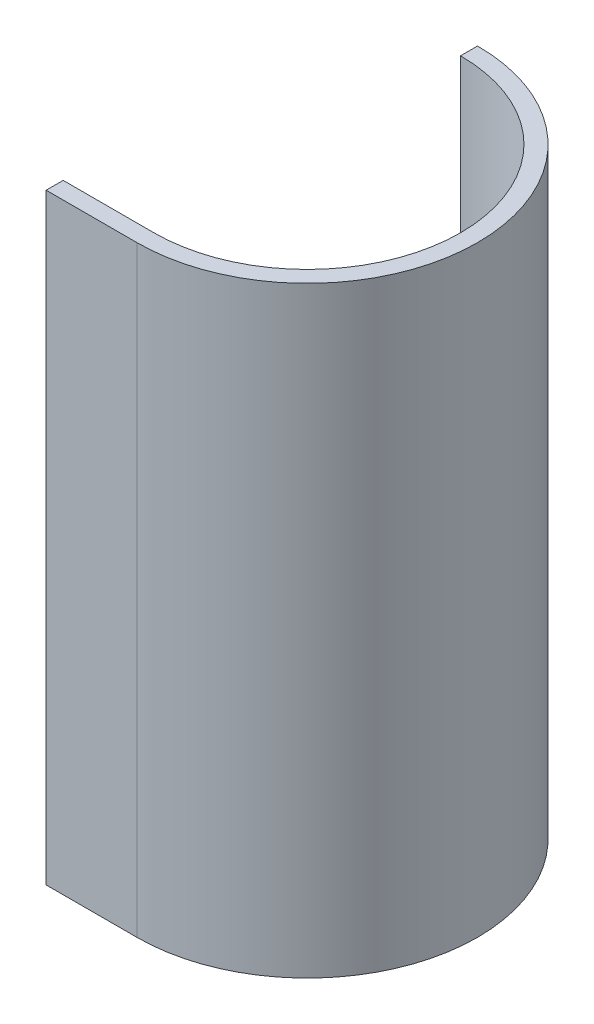
from build123d import *

# Parameters (mm, degrees)
BOSS_EXTRUDE1_DEPTH = 53


with BuildPart() as part:
    # Sketch1 → Boss-Extrude1 (new body)
    with BuildSketch(Plane(origin=(0, 0, 0), x_dir=(1, 0, 0), z_dir=(0, 1, 0))):
        with BuildLine():
            Line((0, 15), (0, 13.5))
            ThreePointArc((0, 13.5), (13.5, 0), (0, -13.5))
            Line((0, -13.5), (-8, -13.5))
            Line((-8, -13.5), (-8, -15))
            Line((-8, -15), (0, -15))
            ThreePointArc((0, -15), (15, 0), (0, 15))
        make_face()
    extrude(amount=BOSS_EXTRUDE1_DEPTH)


solid = part.part
